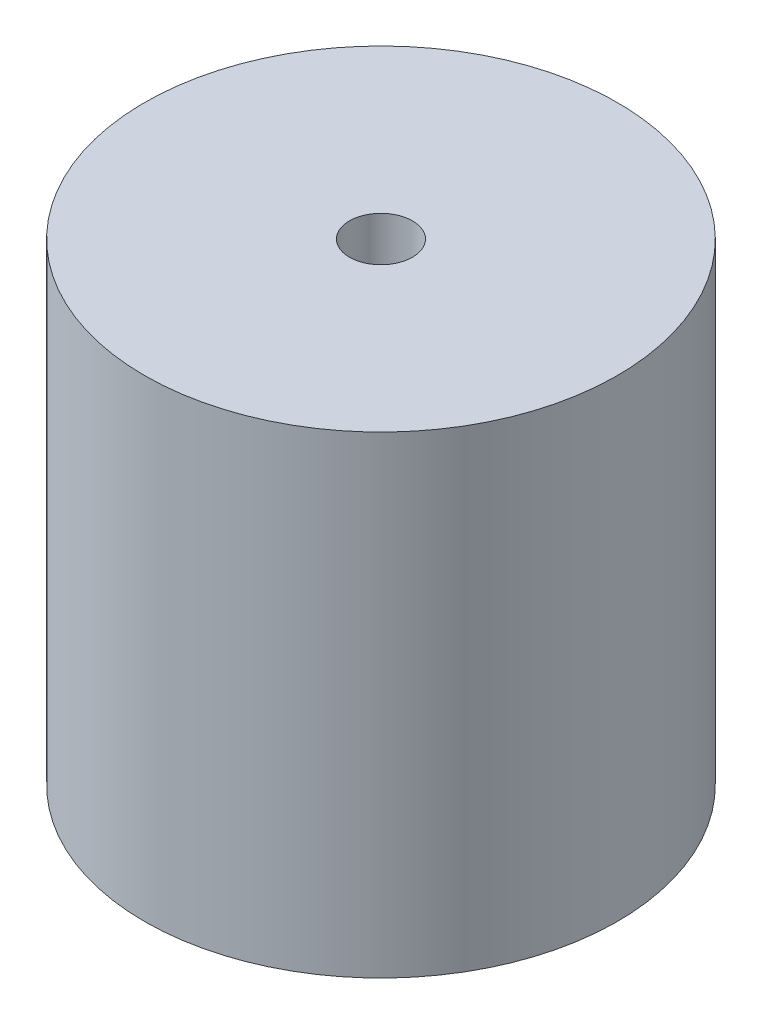
from build123d import *

# Parameters (mm, degrees)
SKETCH1_R           = 15
BOSS_EXTRUDE1_DEPTH = 30
SKETCH2_R           = 2
CUT_EXTRUDE1_DEPTH  = 30


with BuildPart() as part:
    # Sketch1 → Boss-Extrude1 (new body)
    with BuildSketch(Plane(origin=(0, 0, 0), x_dir=(1, 0, 0), z_dir=(0, 1, 0))):
        Circle(SKETCH1_R)
    extrude(amount=BOSS_EXTRUDE1_DEPTH)

    # Sketch2 → Cut-Extrude1 (cut)
    with BuildSketch(Plane(origin=(0, 0, 0), x_dir=(1, 0, 0), z_dir=(0, 1, 0))):
        Circle(SKETCH2_R)
    extrude(amount=CUT_EXTRUDE1_DEPTH, mode=Mode.SUBTRACT)


solid = part.part
